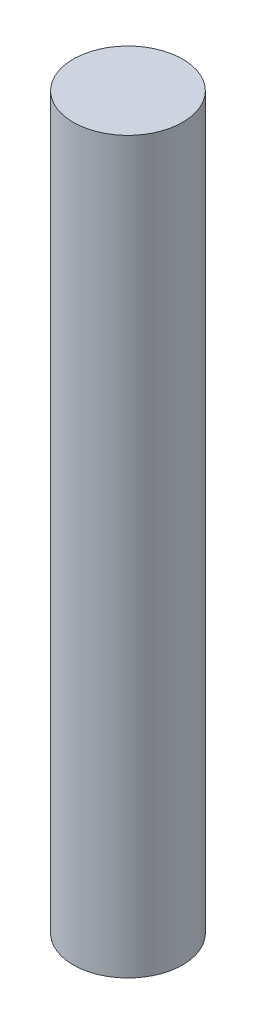
from build123d import *

# Parameters (mm, degrees)
SKETCH1_R           = 3
BOSS_EXTRUDE1_DEPTH = 20


with BuildPart() as part:
    # Sketch1 → Boss-Extrude1 (new body, symmetric)
    with BuildSketch(Plane(origin=(0, 0, 0), x_dir=(1, 0, 0), z_dir=(0, 1, 0))):
        Circle(SKETCH1_R)
    extrude(amount=BOSS_EXTRUDE1_DEPTH, both=True)


solid = part.part
